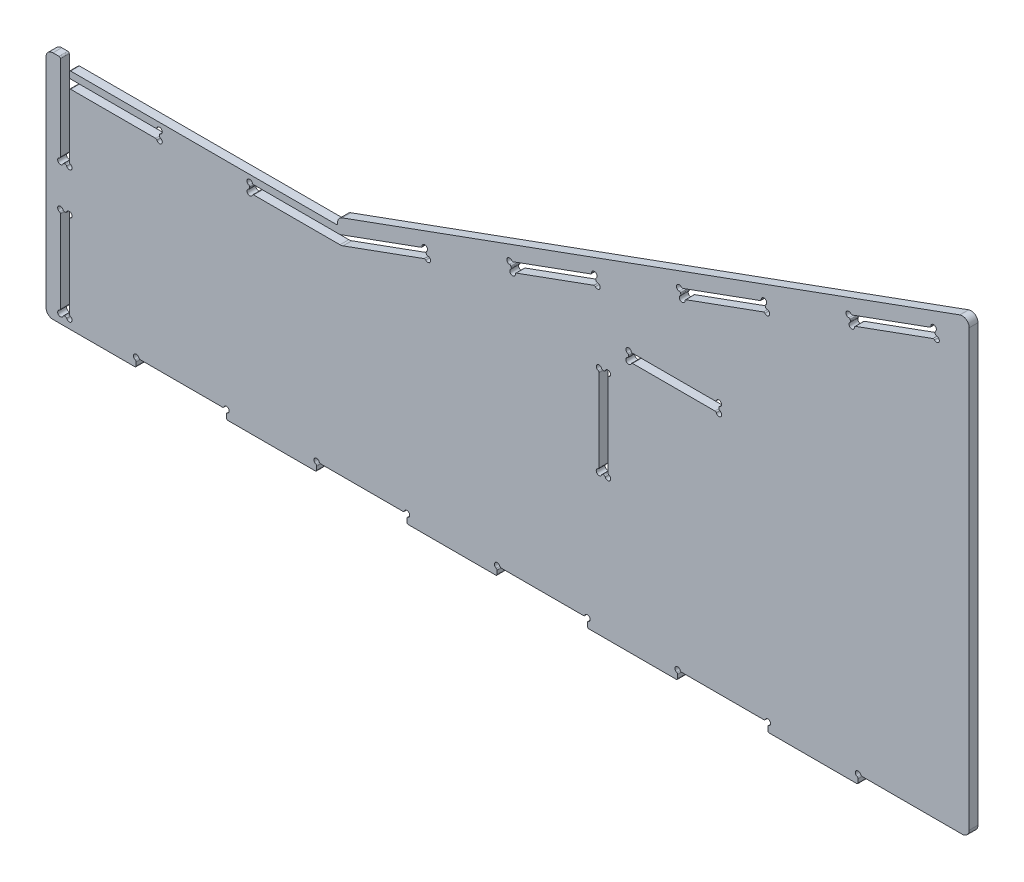
from build123d import *

# Parameters (mm, degrees)
SKETCH1_W           = 812.8
SKETCH1_H           = 457.2
BOSS_EXTRUDE1_DEPTH = 3.175
SKETCH4_OUTSIDE_W   = 1001.318
SKETCH4_OUTSIDE_H   = 645.718
CUT_EXTRUDE3_DEPTH  = 6.35
SKETCH5_W           = 65
SKETCH5_H           = 6.35
BOSS_EXTRUDE2_DEPTH = 6.35
LPATTERN2_COUNT     = 5
LPATTERN2_PITCH     = 130
SKETCH6_R           = 2
CUT_EXTRUDE4_DEPTH  = 7.35
FILLET2_R           = 1
CUT_EXTRUDE5_DEPTH  = 7.35
LPATTERN3_COUNT     = 4
LPATTERN3_PITCH     = 130
SKETCH18_R          = 2
CUT_EXTRUDE13_DEPTH = 7.35
FILLET8_R           = 1
SKETCH10_W          = 6.35
SKETCH10_H          = 65
CUT_EXTRUDE7_DEPTH  = 7.35
SKETCH11_R          = 2
CUT_EXTRUDE8_DEPTH  = 7.35
SKETCH19_W          = 193.236730193
SKETCH19_H          = 5
CUT_EXTRUDE14_DEPTH = 7.35
FILLET4_R           = 1
SKETCH12_R          = 2
CUT_EXTRUDE9_DEPTH  = 7.35
CUT_EXTRUDE10_DEPTH = 7.35
LPATTERN4_COUNT     = 3
LPATTERN4_PITCH     = 130
SKETCH14_W          = 6.35
SKETCH14_H          = 65
SKETCH14_W_2        = 65
SKETCH14_H_2        = 6.35
CUT_EXTRUDE11_DEPTH = 7.35
SKETCH15_R          = 2
CUT_EXTRUDE12_DEPTH = 7.35
FILLET7_R           = 1
FILLET9_R           = 5


with BuildPart() as part:
    # Sketch1 → Boss-Extrude1 (new body, symmetric)
    with BuildSketch(Plane.XY):
        with Locations((406.4, 228.6)):
            Rectangle(SKETCH1_W, SKETCH1_H)
    extrude(amount=BOSS_EXTRUDE1_DEPTH, both=True)

    # Sketch4 outside → Cut-Extrude3 (cut)
    with BuildSketch(Plane.XY.offset(3.175)):
        with Locations((406.4, 228.6)):
            Rectangle(SKETCH4_OUTSIDE_W, SKETCH4_OUTSIDE_H)
        Polygon((10, 16.35), (675, 16.35), (675, 341.956456591), (220, 176.35), (10, 176.35), align=None, mode=Mode.SUBTRACT)
    extrude(amount=-CUT_EXTRUDE3_DEPTH, mode=Mode.SUBTRACT)

    # Sketch5 → Boss-Extrude2 (add)
    with BuildSketch(Plane.XY.offset(3.175)):
        with Locations((42.5, 13.175)):
            Rectangle(SKETCH5_W, SKETCH5_H)
    boss_extrude2 = extrude(amount=-BOSS_EXTRUDE2_DEPTH)

    # LPattern2: Boss-Extrude2 ×5
    with Locations(*[(i * LPATTERN2_PITCH, 0, 0) for i in range(1, LPATTERN2_COUNT)]):
        add(boss_extrude2)

    # Sketch6 → Cut-Extrude4 (cut, through all)
    with BuildSketch(Plane.XY.offset(3.175)):
        with Locations((75, 16.35)):
            Circle(SKETCH6_R)
        with Locations((140, 16.35)):
            Circle(SKETCH6_R)
    extrude(amount=-CUT_EXTRUDE4_DEPTH, mode=Mode.SUBTRACT)

    # Fillet2
    fillet2_edges = [part.edges().sort_by_distance(p)[0] for p in [
        (75, 10, 0),
        (140, 10, 0),
    ]]
    fillet(fillet2_edges, radius=FILLET2_R)

    # Sketch7 → Cut-Extrude5 (cut, through all)
    with BuildSketch(Plane.XY.offset(3.175)):
        with BuildLine():
            Line((140, 13.521572875), (140, 11))
            ThreePointArc((140, 11), (140.292893219, 10.292893219), (141, 10))
            Line((141, 10), (74, 10))
            ThreePointArc((74, 10), (74.707106781, 10.292893219), (75, 11))
            Line((75, 11), (75, 13.521572875))
            ThreePointArc((75, 13.521572875), (74.816496581, 14.098923144), (74.333333333, 14.464381917))
            ThreePointArc((74.333333333, 14.464381917), (73.585786438, 17.764213562), (76.885618083, 17.016666667))
            ThreePointArc((76.885618083, 17.016666667), (77.251076856, 16.533503419), (77.828427125, 16.35))
            Line((77.828427125, 16.35), (137.171572875, 16.35))
            ThreePointArc((137.171572875, 16.35), (137.748923144, 16.533503419), (138.114381917, 17.016666667))
            ThreePointArc((138.114381917, 17.016666667), (141.414213562, 17.764213562), (140.666666667, 14.464381917))
            ThreePointArc((140.666666667, 14.464381917), (140.183503419, 14.098923144), (140, 13.521572875))
        make_face()
    cut_extrude5 = extrude(amount=-CUT_EXTRUDE5_DEPTH, mode=Mode.SUBTRACT)

    # LPattern3: Cut-Extrude5 ×4
    with Locations(*[(i * LPATTERN3_PITCH, 0, 0) for i in range(1, LPATTERN3_COUNT)]):
        add(cut_extrude5, mode=Mode.SUBTRACT)

    # Sketch18 → Cut-Extrude13 (cut, through all)
    with BuildSketch(Plane.XY.offset(3.175)):
        with Locations((595, 16.35)):
            Circle(SKETCH18_R)
    extrude(amount=-CUT_EXTRUDE13_DEPTH, mode=Mode.SUBTRACT)

    # Fillet8
    fillet8_edges = [part.edges().sort_by_distance(p)[0] for p in [
        (595, 10, 0),
        (595, 14.35, 0),
        (597, 16.35, 0),
    ]]
    fillet(fillet8_edges, radius=FILLET8_R)

    # Sketch10 → Cut-Extrude7 (cut, through all)
    with BuildSketch(Plane.XY.offset(3.175)):
        with Locations((23.588269807, 48.85)):
            Rectangle(SKETCH10_W, SKETCH10_H)
        Polygon((20.413269807, 176.35), (20.413269807, 111.35), (26.763269807, 111.35), (26.763269807, 160), (91.763269807, 160), (91.763269807, 166.35), (26.763269807, 166.35), (26.763269807, 176.35), align=None)
        Polygon((466.083351211, 255.275237265), (468.255179122, 249.308189123), (529.335199473, 271.539498439), (527.163371563, 277.506546581), align=None)
        Polygon((588.243391914, 299.737855897), (590.415219824, 293.770807755), (651.495240175, 316.002117071), (649.323412265, 321.969165213), align=None)
        Polygon((343.923310509, 210.812618632), (346.095138419, 204.84557049), (407.17515877, 227.076879807), (405.00333086, 233.043927949), align=None)
        with BuildLine():
            Line((156.763269807, 160), (221.763269807, 160))
            ThreePointArc((221.763269807, 160), (222.865935735, 160.096470768), (223.935097717, 160.382951858))
            Line((223.935097717, 160.382951858), (285.015118068, 182.614261174))
            Line((285.015118068, 182.614261174), (282.843290158, 188.581309316))
            Line((282.843290158, 188.581309316), (221.763269807, 166.35))
            Line((221.763269807, 166.35), (156.763269807, 166.35))
            Line((156.763269807, 166.35), (156.763269807, 160))
        make_face()
    extrude(amount=-CUT_EXTRUDE7_DEPTH, mode=Mode.SUBTRACT)

    # Sketch11 → Cut-Extrude8 (cut, through all)
    with BuildSketch(Plane.XY.offset(3.175)):
        with Locations((20.413269807, 16.35)):
            Circle(SKETCH11_R)
        with Locations((26.763269807, 16.35)):
            Circle(SKETCH11_R)
        with Locations((26.763269807, 81.35)):
            Circle(SKETCH11_R)
        with Locations((20.413269807, 81.35)):
            Circle(SKETCH11_R)
        with Locations((20.413269807, 111.35)):
            Circle(SKETCH11_R)
        with Locations((26.763269807, 111.35)):
            Circle(SKETCH11_R)
        with Locations((91.763269807, 160)):
            Circle(SKETCH11_R)
        with Locations((91.763269807, 166.35)):
            Circle(SKETCH11_R)
        with Locations((156.763269807, 166.35)):
            Circle(SKETCH11_R)
        with Locations((156.763269807, 160)):
            Circle(SKETCH11_R)
        with Locations((282.843290158, 188.581309316)):
            Circle(SKETCH11_R)
        with Locations((285.015118068, 182.614261174)):
            Circle(SKETCH11_R)
    extrude(amount=-CUT_EXTRUDE8_DEPTH, mode=Mode.SUBTRACT)

    # Sketch19 → Cut-Extrude14 (cut, through all)
    with BuildSketch(Plane.XY.offset(3.175)):
        with Locations((123.381634904, 173.85)):
            Rectangle(SKETCH19_W, SKETCH19_H)
    extrude(amount=-CUT_EXTRUDE14_DEPTH, mode=Mode.SUBTRACT)

    # Fillet4
    fillet4_edges = [part.edges().sort_by_distance(p)[0] for p in [
        (20.413269807, 176.35, 0),
        (26.763269807, 166.35, 0),
        (26.763269807, 160, 0),
        (221.763269807, 166.35, 0),
        (20.413269807, 113.35, 0),
        (24.763269807, 111.35, 0),
        (89.763269807, 160, 0),
        (91.763269807, 164.35, 0),
        (20.413269807, 18.35, 0),
        (20.413269807, 79.35, 0),
        (24.763269807, 16.35, 0),
        (26.763269807, 79.35, 0),
        (156.763269807, 162, 0),
        (156.763269807, 164.35, 0),
        (283.135732827, 181.930220888, 0),
        (283.527330445, 186.701924075, 0),
        (158.763269807, 166.35, 0),
        (89.763269807, 166.35, 0),
        (91.763269807, 162, 0),
        (26.763269807, 113.35, 0),
        (22.413269807, 111.35, 0),
        (22.413269807, 81.35, 0),
        (24.763269807, 81.35, 0),
        (26.763269807, 18.35, 0),
        (284.331077782, 184.493646416, 0),
        (280.963904917, 187.89726903, 0),
        (158.763269807, 160, 0),
        (22.413269807, 16.35, 0),
        (220, 171.35, 0),
        (26.763269807, 171.35, 0),
    ]]
    fillet(fillet4_edges, radius=FILLET4_R)

    # Sketch12 → Cut-Extrude9 (cut, through all)
    with BuildSketch(Plane.XY.offset(3.175)):
        with Locations((588.243391914, 299.737855897)):
            Circle(SKETCH12_R)
        with Locations((590.415219824, 293.770807755)):
            Circle(SKETCH12_R)
        with Locations((649.323412265, 321.969165213)):
            Circle(SKETCH12_R)
        with Locations((651.495240175, 316.002117071)):
            Circle(SKETCH12_R)
    extrude(amount=-CUT_EXTRUDE9_DEPTH, mode=Mode.SUBTRACT)

    # Sketch13 → Cut-Extrude10 (cut, through all)
    with BuildSketch(Plane.XY.offset(3.175)):
        with BuildLine():
            Line((593.073071921, 294.738186806), (648.837388077, 315.034738021))
            ThreePointArc((648.837388077, 315.034738021), (649.44268173, 315.059766634), (649.951352205, 314.730735957))
            ThreePointArc((649.951352205, 314.730735957), (653.307855749, 315.156880548), (651.476782555, 318.002031898))
            ThreePointArc((651.476782555, 318.002031898), (650.897763355, 318.180199247), (650.527861124, 318.659969169))
            Line((650.527861124, 318.659969169), (650.290791315, 319.311313116))
            ThreePointArc((650.290791315, 319.311313116), (650.265762702, 319.916606769), (650.594793379, 320.425277244))
            ThreePointArc((650.594793379, 320.425277244), (650.168648788, 323.781780787), (647.323497437, 321.950707593))
            ThreePointArc((647.323497437, 321.950707593), (647.145330089, 321.371688393), (646.665560167, 321.001786163))
            Line((646.665560167, 321.001786163), (590.901244011, 300.705234948))
            ThreePointArc((590.901244011, 300.705234948), (590.295950358, 300.680206335), (589.787279883, 301.009237011))
            ThreePointArc((589.787279883, 301.009237011), (586.43077634, 300.58309242), (588.261849533, 297.73794107))
            ThreePointArc((588.261849533, 297.73794107), (588.840868734, 297.559773721), (589.210770964, 297.080003799))
            Line((589.210770964, 297.080003799), (589.447840773, 296.428659853))
            ThreePointArc((589.447840773, 296.428659853), (589.472869386, 295.823366199), (589.143838709, 295.314695725))
            ThreePointArc((589.143838709, 295.314695725), (589.5699833, 291.958192181), (592.415134651, 293.789265375))
            ThreePointArc((592.415134651, 293.789265375), (592.593301999, 294.368284575), (593.073071921, 294.738186806))
        make_face()
    cut_extrude10 = extrude(amount=-CUT_EXTRUDE10_DEPTH, mode=Mode.SUBTRACT)

    # LPattern4: Cut-Extrude10 ×3
    with Locations(*[Vector(-0.939692621, -0.342020143, 0) * (i * LPATTERN4_PITCH) for i in range(1, LPATTERN4_COUNT)]):
        add(cut_extrude10, mode=Mode.SUBTRACT)

    # Sketch14 → Cut-Extrude11 (cut, through all)
    with BuildSketch(Plane.XY.offset(3.175)):
        with Locations((411.531634904, 143.85)):
            Rectangle(SKETCH14_W, SKETCH14_H)
        with Locations((462.206634904, 194.525)):
            Rectangle(SKETCH14_W_2, SKETCH14_H_2)
    extrude(amount=-CUT_EXTRUDE11_DEPTH, mode=Mode.SUBTRACT)

    # Sketch15 → Cut-Extrude12 (cut, through all)
    with BuildSketch(Plane.XY.offset(3.175)):
        with Locations((408.356634904, 176.35)):
            Circle(SKETCH15_R)
        with Locations((414.706634904, 176.35)):
            Circle(SKETCH15_R)
        with Locations((408.356634904, 111.35)):
            Circle(SKETCH15_R)
        with Locations((414.706634904, 111.35)):
            Circle(SKETCH15_R)
        with Locations((429.706634904, 197.7)):
            Circle(SKETCH15_R)
        with Locations((429.706634904, 191.35)):
            Circle(SKETCH15_R)
        with Locations((494.706634904, 191.35)):
            Circle(SKETCH15_R)
        with Locations((494.706634904, 197.7)):
            Circle(SKETCH15_R)
    extrude(amount=-CUT_EXTRUDE12_DEPTH, mode=Mode.SUBTRACT)

    # Fillet7
    fillet7_edges = [part.edges().sort_by_distance(p)[0] for p in [
        (410.356634904, 111.35, 0),
        (412.706634904, 111.35, 0),
        (414.706634904, 174.35, 0),
        (410.356634904, 176.35, 0),
        (429.706634904, 193.35, 0),
        (429.706634904, 195.7, 0),
        (492.706634904, 191.35, 0),
        (494.706634904, 195.7, 0),
        (431.706634904, 197.7, 0),
        (414.706634904, 113.35, 0),
        (408.356634904, 113.35, 0),
        (412.706634904, 176.35, 0),
        (431.706634904, 191.35, 0),
        (494.706634904, 193.35, 0),
        (492.706634904, 197.7, 0),
        (408.356634904, 174.35, 0),
    ]]
    fillet(fillet7_edges, radius=FILLET7_R)

    # Fillet9
    fillet9_edges = [part.edges().sort_by_distance(p)[0] for p in [
        (10, 176.35, 0),
        (220, 176.35, 0),
        (675, 341.956456591, 0),
        (675, 16.35, 0),
        (10, 10, 0),
    ]]
    fillet(fillet9_edges, radius=FILLET9_R)


solid = part.part
